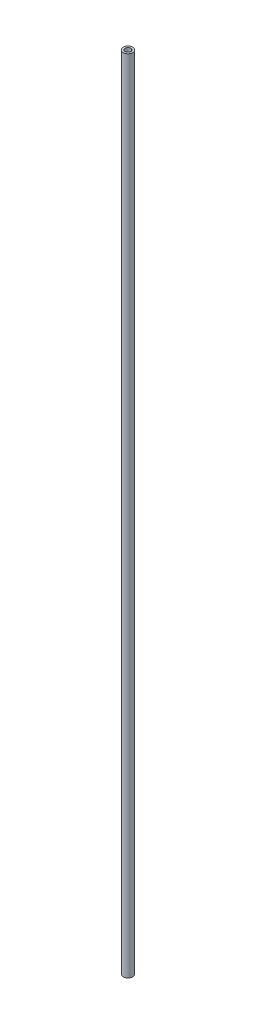
from build123d import *

# Parameters (mm, degrees)
SKETCH2_R           = 2.5
SKETCH2_R_2         = 1.5
BOSS_EXTRUDE3_DEPTH = 209.5


with BuildPart() as part:
    # Sketch2 → Boss-Extrude3 (new body, symmetric)
    with BuildSketch(Plane(origin=(0, 0, 0), x_dir=(1, 0, 0), z_dir=(0, 1, 0))):
        Circle(SKETCH2_R)
        Circle(SKETCH2_R_2, mode=Mode.SUBTRACT)
    extrude(amount=BOSS_EXTRUDE3_DEPTH, both=True)


solid = part.part
